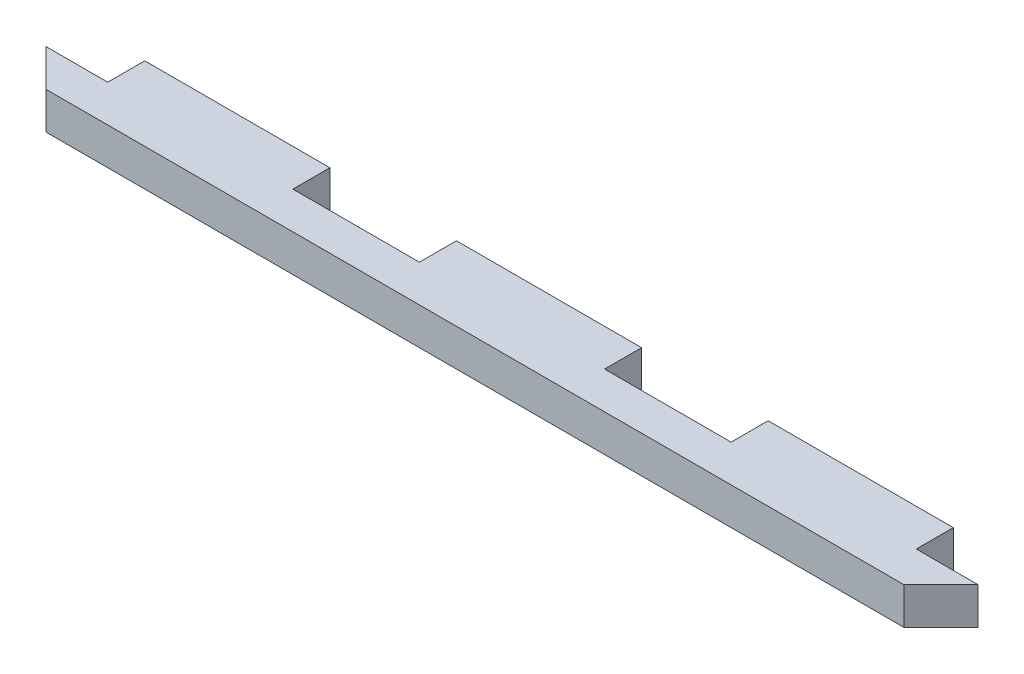
from build123d import *

# Parameters (mm, degrees)
BOSS_EXTRUDE1_DEPTH = 6
SKETCH3_W           = 30
SKETCH3_H           = 6
BOSS_EXTRUDE2_DEPTH = 6


with BuildPart() as part:
    # Sketch1 → Boss-Extrude1 (new body)
    with BuildSketch(Plane(origin=(0, 0, 0), x_dir=(1, 0, 0), z_dir=(0, 1, 0))):
        Polygon((75.5, 3), (-75.5, 3), (-69.5, -3), (69.5, -3), align=None)
    extrude(amount=BOSS_EXTRUDE1_DEPTH)

    # Sketch3 → Boss-Extrude2 (add)
    with BuildSketch(Plane.XZ):
        with Locations((50.5, -6)):
            Rectangle(SKETCH3_W, SKETCH3_H)
        with Locations((0, -6)):
            Rectangle(SKETCH3_W, SKETCH3_H)
        with Locations((-50.5, -6)):
            Rectangle(SKETCH3_W, SKETCH3_H)
    extrude(amount=-BOSS_EXTRUDE2_DEPTH)


solid = part.part
